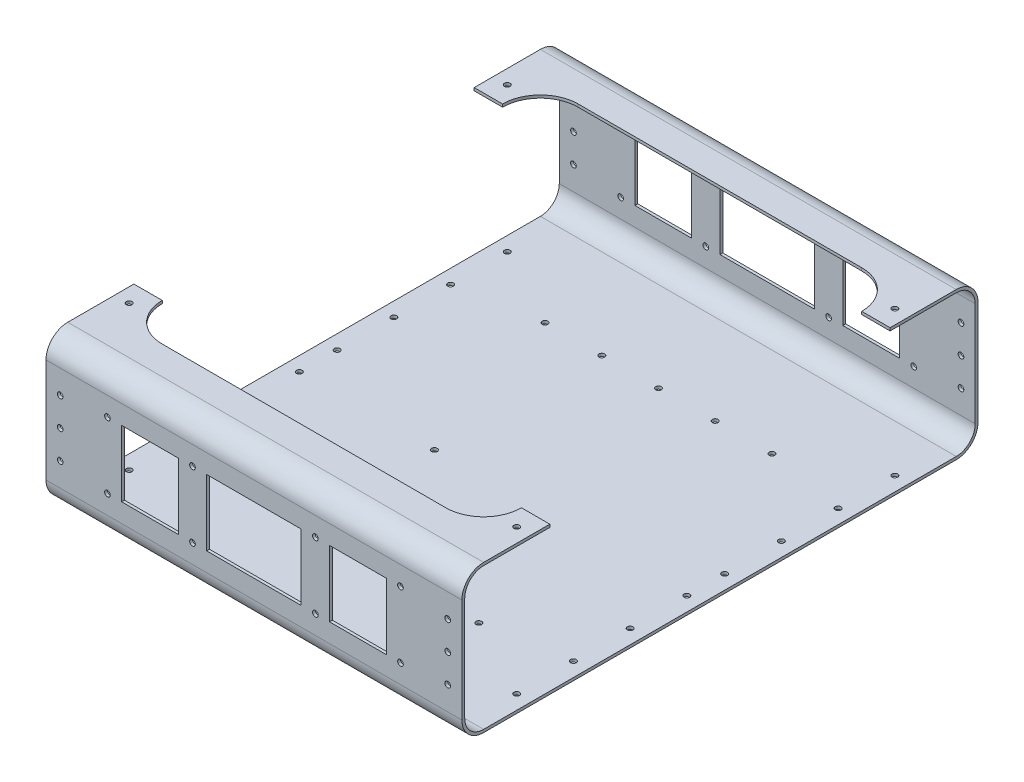
from build123d import *

# Parameters (mm, degrees)
BOSS_EXTRUDE1_DEPTH     = 220
CUT_EXTRUDE1_DEPTH      = 10
SKETCH3_R               = 1.5
SKETCH3_W               = 30
SKETCH3_H               = 35
SKETCH3_W_2             = 50
CUT_EXTRUDE2_DEPTH      = 274
SKETCH5_R               = 1.5
CUT_EXTRUDE3_DEPTH      = 10
SKETCH6_R               = 1.5
CUT_EXTRUDE4_DEPTH      = 10
SKETCH7_R               = 1.5
CUT_EXTRUDE5_DEPTH      = 77.5
CUT_EXTRUDE5_DEPTH_BACK = 2.5
SKETCH8_R               = 1.5
CUT_EXTRUDE6_DEPTH      = 79
SKETCH9_R               = 1.5
CUT_EXTRUDE7_DEPTH      = 274


with BuildPart() as part:
    # Sketch1 → Boss-Extrude1 (new body)
    with BuildSketch(Plane(origin=(0, 0, 0), x_dir=(0, 0, -1), z_dir=(1, 0, 0))):
        with BuildLine():
            Line((-125, 39), (125, 39))
            ThreePointArc((125, 39), (133.131727984, 35.631727984), (136.5, 27.5))
            Line((136.5, 27.5), (136.5, -27.5))
            ThreePointArc((136.5, -27.5), (133.131727984, -35.631727984), (125, -39))
            Line((125, -39), (-125, -39))
            ThreePointArc((-125, -39), (-133.131727984, -35.631727984), (-136.5, -27.5))
            Line((-136.5, -27.5), (-136.5, 27.5))
            ThreePointArc((-136.5, 27.5), (-133.131727984, 35.631727984), (-125, 39))
        make_face()
        with BuildLine():
            Line((-125, 37.5), (125, 37.5))
            ThreePointArc((125, 37.5), (132.071067812, 34.571067812), (135, 27.5))
            Line((135, 27.5), (135, -27.5))
            ThreePointArc((135, -27.5), (132.071067812, -34.571067812), (125, -37.5))
            Line((125, -37.5), (-125, -37.5))
            ThreePointArc((-125, -37.5), (-132.071067812, -34.571067812), (-135, -27.5))
            Line((-135, -27.5), (-135, 27.5))
            ThreePointArc((-135, 27.5), (-132.071067812, 34.571067812), (-125, 37.5))
        make_face(mode=Mode.SUBTRACT)
    extrude(amount=BOSS_EXTRUDE1_DEPTH)

    # Sketch2 → Cut-Extrude1 (cut)
    with BuildSketch(Plane(origin=(0, 39, 0), x_dir=(1, 0, 0), z_dir=(0, 1, 0))):
        with BuildLine():
            Line((15, 90), (0, 90))
            Line((0, 90), (0, -90))
            Line((0, -90), (15, -90))
            ThreePointArc((15, -90), (20.857864376, -104.142135624), (35, -110))
            Line((35, -110), (185, -110))
            ThreePointArc((185, -110), (199.142135624, -104.142135624), (205, -90))
            Line((205, -90), (220, -90))
            Line((220, -90), (220, 90))
            Line((220, 90), (205, 90))
            ThreePointArc((205, 90), (199.142135624, 104.142135624), (185, 110))
            Line((185, 110), (35, 110))
            ThreePointArc((35, 110), (20.857864376, 104.142135624), (15, 90))
        make_face()
    extrude(amount=-CUT_EXTRUDE1_DEPTH, mode=Mode.SUBTRACT)

    # Sketch3 → Cut-Extrude2 (cut, through all)
    with BuildSketch(Plane.XY.offset(136.5)):
        with Locations((77.5, 17.5)):
            Circle(SKETCH3_R)
        with Locations((77.5, -17.5)):
            Circle(SKETCH3_R)
        with Locations((142.5, 17.5)):
            Circle(SKETCH3_R)
        with Locations((142.5, -17.5)):
            Circle(SKETCH3_R)
        with Locations((32.5, 17.5)):
            Circle(SKETCH3_R)
        with Locations((32.5, -17.5)):
            Circle(SKETCH3_R)
        with Locations((187.5, 17.5)):
            Circle(SKETCH3_R)
        with Locations((187.5, -17.5)):
            Circle(SKETCH3_R)
        with Locations((55, 0)):
            Rectangle(SKETCH3_W, SKETCH3_H)
        with Locations((165, 0)):
            Rectangle(SKETCH3_W, SKETCH3_H)
        with Locations((110, 0)):
            Rectangle(SKETCH3_W_2, SKETCH3_H)
    extrude(amount=-CUT_EXTRUDE2_DEPTH, mode=Mode.SUBTRACT)

    # Sketch5 → Cut-Extrude3 (cut)
    with BuildSketch(Plane(origin=(0, -37.5, 0), x_dir=(1, 0, 0), z_dir=(0, 1, 0))):
        with Locations((79, -55)):
            Circle(SKETCH5_R)
        with Locations((79, -10)):
            Circle(SKETCH5_R)
    extrude(amount=-CUT_EXTRUDE3_DEPTH, mode=Mode.SUBTRACT)

    # Sketch6 → Cut-Extrude4 (cut)
    with BuildSketch(Plane(origin=(0, -37.5, 0), x_dir=(1, 0, 0), z_dir=(0, 1, 0))):
        with Locations((110, -77.5)):
            Circle(SKETCH6_R)
        with Locations((140, -77.5)):
            Circle(SKETCH6_R)
        with Locations((170, -77.5)):
            Circle(SKETCH6_R)
        with Locations((80, -77.5)):
            Circle(SKETCH6_R)
        with Locations((50, -77.5)):
            Circle(SKETCH6_R)
        with Locations((110, 77.5)):
            Circle(SKETCH6_R)
        with Locations((140, 77.5)):
            Circle(SKETCH6_R)
        with Locations((170, 77.5)):
            Circle(SKETCH6_R)
        with Locations((80, 77.5)):
            Circle(SKETCH6_R)
        with Locations((50, 77.5)):
            Circle(SKETCH6_R)
    extrude(amount=-CUT_EXTRUDE4_DEPTH, mode=Mode.SUBTRACT)

    # Sketch7 → Cut-Extrude5 (cut, two sides)
    with BuildSketch(Plane(origin=(0, -37.5, 0), x_dir=(1, 0, 0), z_dir=(0, 1, 0))) as cut_extrude5_sk:
        with Locations((7.5, 10)):
            Circle(SKETCH7_R)
        with Locations((7.5, -10)):
            Circle(SKETCH7_R)
        with Locations((7.5, -40)):
            Circle(SKETCH7_R)
        with Locations((7.5, -70)):
            Circle(SKETCH7_R)
        with Locations((7.5, -100)):
            Circle(SKETCH7_R)
        with Locations((7.5, 40)):
            Circle(SKETCH7_R)
        with Locations((7.5, 70)):
            Circle(SKETCH7_R)
        with Locations((7.5, 100)):
            Circle(SKETCH7_R)
    extrude(amount=CUT_EXTRUDE5_DEPTH, mode=Mode.SUBTRACT)
    extrude(cut_extrude5_sk.sketch, amount=-CUT_EXTRUDE5_DEPTH_BACK, mode=Mode.SUBTRACT)

    # Sketch8 → Cut-Extrude6 (cut, through all)
    with BuildSketch(Plane.XZ.offset(39)):
        with Locations((212.5, 10)):
            Circle(SKETCH8_R)
        with Locations((212.5, -10)):
            Circle(SKETCH8_R)
        with Locations((212.5, -40)):
            Circle(SKETCH8_R)
        with Locations((212.5, -70)):
            Circle(SKETCH8_R)
        with Locations((212.5, -100)):
            Circle(SKETCH8_R)
        with Locations((212.5, 40)):
            Circle(SKETCH8_R)
        with Locations((212.5, 70)):
            Circle(SKETCH8_R)
        with Locations((212.5, 100)):
            Circle(SKETCH8_R)
    extrude(amount=-CUT_EXTRUDE6_DEPTH, mode=Mode.SUBTRACT)

    # Sketch9 → Cut-Extrude7 (cut, through all)
    with BuildSketch(Plane(origin=(0, 0, -136.5), x_dir=(-1, 0, 0), z_dir=(0, 0, -1))):
        with Locations((-7.5, 0)):
            Circle(SKETCH9_R)
        with Locations((-7.5, 15)):
            Circle(SKETCH9_R)
        with Locations((-7.5, -15)):
            Circle(SKETCH9_R)
        with Locations((-212.5, 0)):
            Circle(SKETCH9_R)
        with Locations((-212.5, 15)):
            Circle(SKETCH9_R)
        with Locations((-212.5, -15)):
            Circle(SKETCH9_R)
    extrude(amount=-CUT_EXTRUDE7_DEPTH, mode=Mode.SUBTRACT)


solid = part.part
